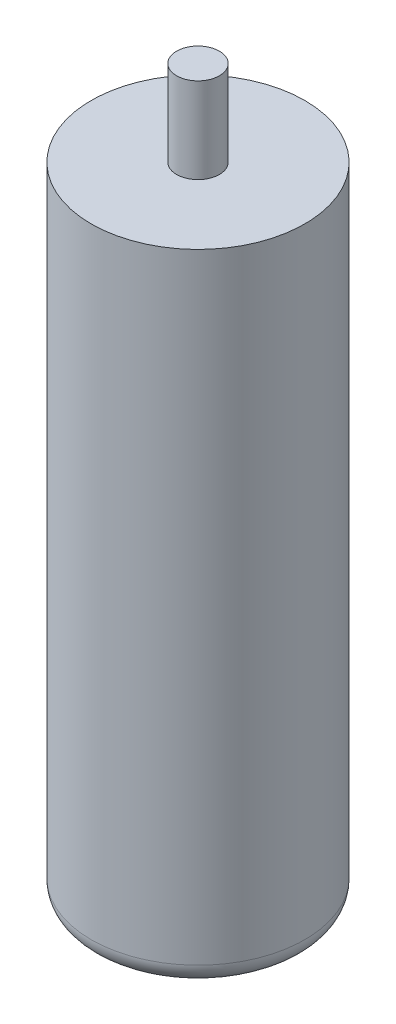
from build123d import *

# Parameters (mm, degrees)
SKETCH1_R           = 25
BOSS_EXTRUDE1_DEPTH = 150
SKETCH2_R           = 5
BOSS_EXTRUDE2_DEPTH = 20
FILLET1_R           = 5


with BuildPart() as part:
    # Sketch1 → Boss-Extrude1 (new body)
    with BuildSketch(Plane(origin=(0, 0, 0), x_dir=(1, 0, 0), z_dir=(0, 1, 0))):
        Circle(SKETCH1_R)
    extrude(amount=BOSS_EXTRUDE1_DEPTH)

    # Sketch2 → Boss-Extrude2 (add)
    with BuildSketch(Plane(origin=(0, 150, 0), x_dir=(1, 0, 0), z_dir=(0, 1, 0))):
        Circle(SKETCH2_R)
    extrude(amount=BOSS_EXTRUDE2_DEPTH)

    # Fillet1
    fillet1_edges = [part.edges().sort_by_distance(p)[0] for p in [
        (-25, 0, 0),
    ]]
    fillet(fillet1_edges, radius=FILLET1_R)


solid = part.part
